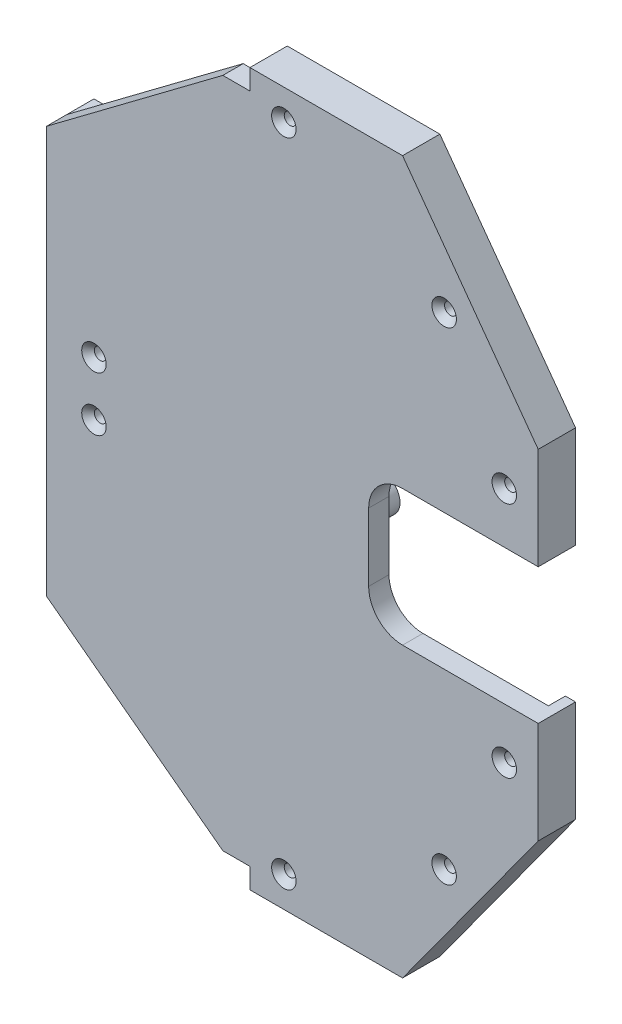
from build123d import *

# Parameters (mm, degrees)
ESTRUSIONE_ESTRUSIONE2_DEPTH = 6
SCHIZZO2_W                   = 25
SCHIZZO2_H                   = 36
ESTRUSIONE_ESTRUSIONE3_DEPTH = 8
TAGLIO_ESTRUSIONE1_DEPTH     = 15
TAGLIO_ESTRUSIONE2_DEPTH     = 10.5
ESTRUSIONE_ESTRUSIONE5_DEPTH = 10
ESTRUSIONE_ESTRUSIONE6_DEPTH = 5
SCHIZZO8_R                   = 1.75
TAGLIO_ESTRUSIONE3_DEPTH     = 17
SCHIZZO9_R                   = 5
SCHIZZO9_R_2                 = 3
ESTRUSIONE_ESTRUSIONE7_DEPTH = 10
RACCORDO1_R                  = 3
SMUSSO1_SIZE                 = 0.5
SMUSSO2_SIZE                 = 1.86


with BuildPart() as part:
    # Schizzo1 → Estrusione-Estrusione2 (new body)
    with BuildSketch(Plane.XY):
        Polygon((-8, -60), (-8, 60), (52, 105), (97, 105), (137, 50), (137, -50), (97, -105), (52, -105), align=None)
    extrude(amount=ESTRUSIONE_ESTRUSIONE2_DEPTH)

    # Schizzo2 → Estrusione-Estrusione3 (add)
    with BuildSketch(Plane(origin=(0, 0, 0), x_dir=(-1, 0, 0), z_dir=(0, 0, -1))):
        with Locations((-4.5, -42)):
            Rectangle(SCHIZZO2_W, SCHIZZO2_H)
        with Locations((-4.5, 42)):
            Rectangle(SCHIZZO2_W, SCHIZZO2_H)
    extrude(amount=ESTRUSIONE_ESTRUSIONE3_DEPTH)

    # Schizzo3 → Taglio-Estrusione1 (cut, through all)
    with BuildSketch(Plane(origin=(0, 0, 6), x_dir=(-1, 0, 0), z_dir=(0, 0, -1))):
        Polygon((-52, 105), (-44, 99), (-52, 99), align=None)
        Polygon((-52, -105), (-44, -99), (-52, -99), align=None)
    extrude(amount=TAGLIO_ESTRUSIONE1_DEPTH, mode=Mode.SUBTRACT)

    # Schizzo4 → Taglio-Estrusione2 (cut)
    with BuildSketch(Plane(origin=(0, 0, -8), x_dir=(-1, 0, 0), z_dir=(0, 0, -1))):
        with BuildLine():
            Line((2.85, 30.0132503), (2.85, 31.8867497))
            ThreePointArc((2.85, 31.8867497), (-3, 30.95), (2.85, 30.0132503))
        make_face()
        with BuildLine():
            Line((2.85, -30.0132503), (2.85, -31.8867497))
            ThreePointArc((2.85, -31.8867497), (-3, -30.95), (2.85, -30.0132503))
        make_face()
    extrude(amount=-TAGLIO_ESTRUSIONE2_DEPTH, mode=Mode.SUBTRACT)

    # Schizzo6 → Estrusione-Estrusione5 (add)
    with BuildSketch(Plane(origin=(0, 0, 0), x_dir=(-1, 0, 0), z_dir=(0, 0, -1))):
        with BuildLine():
            Line((-65, -5.25), (-75, -5.25))
            ThreePointArc((-75, -5.25), (-80.25, 0), (-75, 5.25))
            Line((-75, 5.25), (-65, 5.25))
            ThreePointArc((-65, 5.25), (-59.75, 0), (-65, -5.25))
        make_face()
        with BuildLine():
            Line((-65, -3.25), (-75, -3.25))
            ThreePointArc((-75, -3.25), (-78.25, 0), (-75, 3.25))
            Line((-75, 3.25), (-65, 3.25))
            ThreePointArc((-65, 3.25), (-61.75, 0), (-65, -3.25))
        make_face(mode=Mode.SUBTRACT)
        with BuildLine():
            Line((-97.192473147, 53.28), (-99.588351187, 53.28))
            ThreePointArc((-99.588351187, 53.28), (-101.00256475, 52.694213562), (-101.588351187, 51.28))
            Line((-101.588351187, 51.28), (-101.588351187, 45.28))
            ThreePointArc((-101.588351187, 45.28), (-101.00256475, 43.865786438), (-99.588351187, 43.28))
            Line((-99.588351187, 43.28), (-88.338351187, 43.28))
            ThreePointArc((-88.338351187, 43.28), (-86.924137625, 43.865786438), (-86.338351187, 45.28))
            Line((-86.338351187, 45.28), (-86.338351187, 46.58848156))
            ThreePointArc((-86.338351187, 46.58848156), (-86.715866817, 47.757902129), (-87.705895655, 48.485848156))
            Line((-87.705895655, 48.485848156), (-92.067947473, 49.939865428))
            ThreePointArc((-92.067947473, 49.939865428), (-92.312116926, 50.004445295), (-92.562478503, 50.037737372))
            ThreePointArc((-92.562478503, 50.037737372), (-94.238582432, 50.643407271), (-95.343283829, 52.041904762))
            ThreePointArc((-95.343283829, 52.041904762), (-96.079775867, 52.94189794), (-97.192473147, 53.28))
        make_face()
        with BuildLine():
            Line((-97.192473147, -53.28), (-99.588351187, -53.28))
            ThreePointArc((-99.588351187, -53.28), (-101.00256475, -52.694213562), (-101.588351187, -51.28))
            Line((-101.588351187, -51.28), (-101.588351187, -45.28))
            ThreePointArc((-101.588351187, -45.28), (-101.00256475, -43.865786438), (-99.588351187, -43.28))
            Line((-99.588351187, -43.28), (-88.338351187, -43.28))
            ThreePointArc((-88.338351187, -43.28), (-86.924137625, -43.865786438), (-86.338351187, -45.28))
            Line((-86.338351187, -45.28), (-86.338351187, -46.58848156))
            ThreePointArc((-86.338351187, -46.58848156), (-86.715866817, -47.757902129), (-87.705895655, -48.485848156))
            Line((-87.705895655, -48.485848156), (-92.067947473, -49.939865428))
            ThreePointArc((-92.067947473, -49.939865428), (-92.312116926, -50.004445295), (-92.562478503, -50.037737372))
            ThreePointArc((-92.562478503, -50.037737372), (-94.238582432, -50.643407271), (-95.343283829, -52.041904762))
            ThreePointArc((-95.343283829, -52.041904762), (-96.079775867, -52.94189794), (-97.192473147, -53.28))
        make_face()
        with BuildLine():
            Line((-75.270403715, -92.59965352), (-79.632455532, -94.053670792))
            ThreePointArc((-79.632455532, -94.053670792), (-80.62248437, -94.781616819), (-81, -95.951037389))
            Line((-81, -95.951037389), (-81, -96.959518948))
            ThreePointArc((-81, -96.959518948), (-80.414213562, -98.373732511), (-79, -98.959518948))
            Line((-79, -98.959518948), (-71, -98.959518948))
            ThreePointArc((-71, -98.959518948), (-68.171572875, -97.787946073), (-67, -94.959518948))
            Line((-67, -94.959518948), (-67, -91.259518948))
            ThreePointArc((-67, -91.259518948), (-67.585786438, -89.845305386), (-69, -89.259518948))
            Line((-69, -89.259518948), (-70.14587804, -89.259518948))
            ThreePointArc((-70.14587804, -89.259518948), (-71.258575321, -89.597621009), (-71.995067358, -90.497614187))
            ThreePointArc((-71.995067358, -90.497614187), (-73.099768755, -91.896111677), (-74.775872685, -92.501781576))
            ThreePointArc((-74.775872685, -92.501781576), (-75.026234261, -92.535073654), (-75.270403715, -92.59965352))
        make_face()
        with BuildLine():
            Line((-70.14587804, 89.259518948), (-69, 89.259518948))
            ThreePointArc((-69, 89.259518948), (-67.585786438, 89.845305386), (-67, 91.259518948))
            Line((-67, 91.259518948), (-67, 94.959518948))
            ThreePointArc((-67, 94.959518948), (-68.171572875, 97.787946073), (-71, 98.959518948))
            Line((-71, 98.959518948), (-79, 98.959518948))
            ThreePointArc((-79, 98.959518948), (-80.414213562, 98.373732511), (-81, 96.959518948))
            Line((-81, 96.959518948), (-81, 95.951037389))
            ThreePointArc((-81, 95.951037389), (-80.62248437, 94.781616819), (-79.632455532, 94.053670792))
            Line((-79.632455532, 94.053670792), (-75.270403715, 92.59965352))
            ThreePointArc((-75.270403715, 92.59965352), (-75.026234261, 92.535073654), (-74.775872685, 92.501781576))
            ThreePointArc((-74.775872685, 92.501781576), (-73.099768755, 91.896111677), (-71.995067358, 90.497614187))
            ThreePointArc((-71.995067358, 90.497614187), (-71.258575321, 89.597621009), (-70.14587804, 89.259518948))
        make_face()
    extrude(amount=ESTRUSIONE_ESTRUSIONE5_DEPTH)

    # Schizzo7 → Estrusione-Estrusione6 (add)
    with BuildSketch(Plane(origin=(0, 0, 0), x_dir=(-1, 0, 0), z_dir=(0, 0, -1))):
        Polygon((-52, -105), (-97, -105), (-137, -50), (-137, 50), (-97, 105), (-52, 105), (-52, 102), (-95.472326225, 102), (-134, 49.024448559), (-134, -49.024448559), (-95.472326225, -102), (-52, -102), align=None)
    extrude(amount=ESTRUSIONE_ESTRUSIONE6_DEPTH)

    # Schizzo8 → Taglio-Estrusione3 (cut, through all)
    with BuildSketch(Plane.XY.offset(6)):
        with Locations((62, 96)):
            Circle(SCHIZZO8_R)
        with Locations((109.263051754, 71.136465702)):
            Circle(SCHIZZO8_R)
        with Locations((127, 35)):
            Circle(SCHIZZO8_R)
        with Locations((127, -35)):
            Circle(SCHIZZO8_R)
        with Locations((109.263051754, -71.136465702)):
            Circle(SCHIZZO8_R)
        with Locations((62, -96)):
            Circle(SCHIZZO8_R)
        with Locations((6, -8)):
            Circle(SCHIZZO8_R)
        with Locations((6, 8)):
            Circle(SCHIZZO8_R)
        with BuildLine():
            Line((137, 20), (97, 20))
            ThreePointArc((97, 20), (89.928932188, 17.071067812), (87, 10))
            Line((87, 10), (87, -10))
            ThreePointArc((87, -10), (89.928932188, -17.071067812), (97, -20))
            Line((97, -20), (137, -20))
            Line((137, -20), (137, 20))
        make_face()
    extrude(amount=-TAGLIO_ESTRUSIONE3_DEPTH, mode=Mode.SUBTRACT)

    # Schizzo9 → Estrusione-Estrusione7 (add)
    with BuildSketch(Plane(origin=(0, 0, 0), x_dir=(-1, 0, 0), z_dir=(0, 0, -1))):
        with Locations((-60, 15.95)):
            Circle(SCHIZZO9_R)
        with Locations((-60, 15.95)):
            Circle(SCHIZZO9_R_2, mode=Mode.SUBTRACT)
        with Locations((-60, -15.95)):
            Circle(SCHIZZO9_R)
        with Locations((-60, -15.95)):
            Circle(SCHIZZO9_R_2, mode=Mode.SUBTRACT)
    extrude(amount=ESTRUSIONE_ESTRUSIONE7_DEPTH)

    # Raccordo1
    raccordo1_edges = [part.edges().sort_by_distance(p)[0] for p in [
        (70, 5.25, 0),
        (80.25, 0, 0),
        (70, -5.25, 0),
        (65, 15.95, 0),
        (65, -15.95, 0),
        (59.75, 0, 0),
    ]]
    fillet(raccordo1_edges, radius=RACCORDO1_R)

    # Smusso1
    smusso1_edges = [part.edges().sort_by_distance(p)[0] for p in [
        (61.75, 0, -10),
        (70, 3.25, -10),
        (78.25, 0, -10),
        (70, -3.25, -10),
        (63, 15.95, -10),
        (63, -15.95, -10),
        (3, -30.95, -8),
        (3, 30.95, -8),
    ]]
    chamfer(smusso1_edges, length=SMUSSO1_SIZE)

    # Smusso2
    smusso2_edges = [part.edges().sort_by_distance(p)[0] for p in [
        (60.25, 96, 6),
        (107.513051754, 71.136465702, 6),
        (125.25, 35, 6),
        (125.25, -35, 6),
        (107.513051754, -71.136465702, 6),
        (60.25, -96, 6),
        (4.25, 8, 6),
        (4.25, -8, 6),
    ]]
    chamfer(smusso2_edges, length=SMUSSO2_SIZE)


solid = part.part
